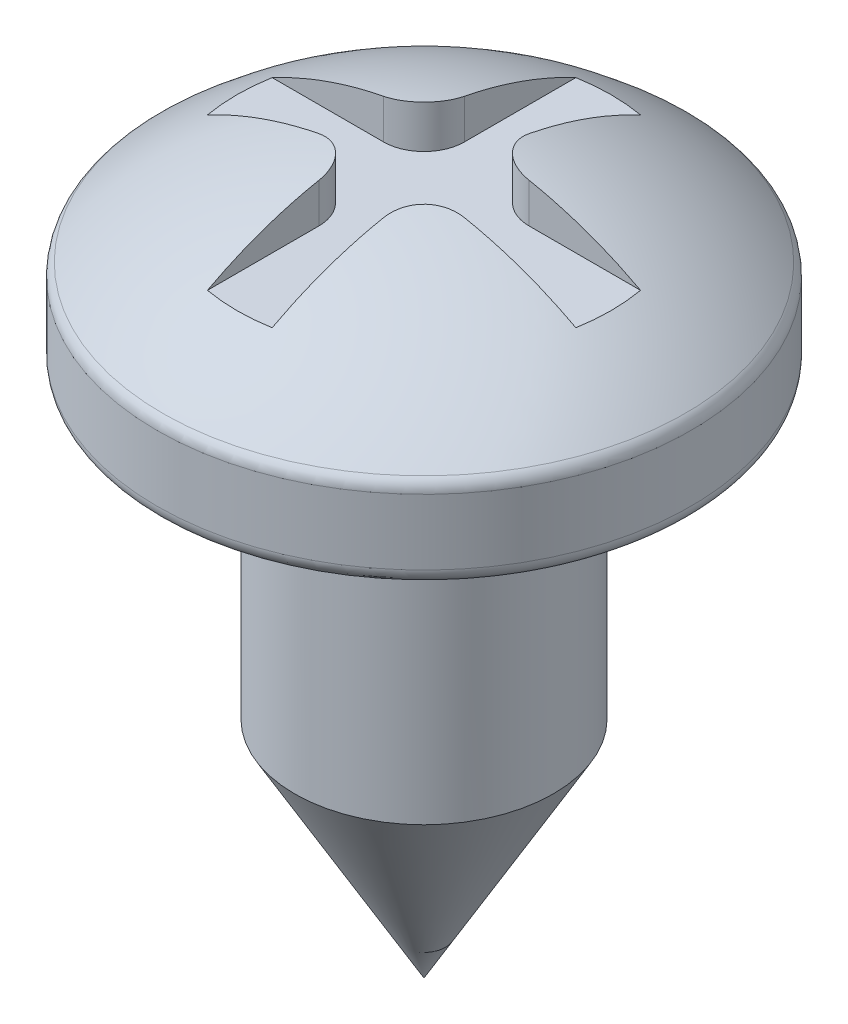
from build123d import *

# Parameters (mm, degrees)
CORTAR_EXTRUIR1_START = -1.8
CORTAR_EXTRUIR1_DEPTH = 3


with BuildPart() as part:
    # Croquis1 → Revolución1 (revolve)
    with BuildSketch(Plane.XY):
        with BuildLine():
            Line((0, 0), (0, 8.9))
            ThreePointArc((0, 8.9), (1.726548348, 8.569000929), (3.231811568, 7.660864252))
            ThreePointArc((3.231811568, 7.660864252), (3.282156956, 7.593022088), (3.3, 7.5104458))
            Line((3.3, 7.5104458), (3.3, 6.7))
            ThreePointArc((3.3, 6.7), (3.241421356, 6.558578644), (3.1, 6.5))
            Line((3.1, 6.5), (1.6, 6.5))
            Line((1.6, 6.5), (1.6, 2.771281292))
            Line((1.6, 2.771281292), (0, 0))
        make_face()
    revolve(axis=Axis((0, 0, 0), (0, 1, 0)))

    # Croquis2 → Cortar-Extruir1 (cut)
    with BuildSketch(Plane.XZ.offset(-6.5).offset(CORTAR_EXTRUIR1_START)):
        with BuildLine():
            Line((-0.4, 3.2), (-0.4, 0.9))
            ThreePointArc((-0.4, 0.9), (-0.546446609, 0.546446609), (-0.9, 0.4))
            Line((-0.9, 0.4), (-3.2, 0.4))
            Line((-3.2, 0.4), (-3.2, -0.4))
            Line((-3.2, -0.4), (-0.9, -0.4))
            ThreePointArc((-0.9, -0.4), (-0.546446609, -0.546446609), (-0.4, -0.9))
            Line((-0.4, -0.9), (-0.4, -3.2))
            Line((-0.4, -3.2), (0.4, -3.2))
            Line((0.4, -3.2), (0.4, -0.9))
            ThreePointArc((0.4, -0.9), (0.546446609, -0.546446609), (0.9, -0.4))
            Line((0.9, -0.4), (3.2, -0.4))
            Line((3.2, -0.4), (3.2, 0.4))
            Line((3.2, 0.4), (0.9, 0.4))
            ThreePointArc((0.9, 0.4), (0.546446609, 0.546446609), (0.4, 0.9))
            Line((0.4, 0.9), (0.4, 3.2))
            Line((0.4, 3.2), (-0.4, 3.2))
        make_face()
    extrude(amount=-CORTAR_EXTRUIR1_DEPTH, mode=Mode.SUBTRACT)


solid = part.part
